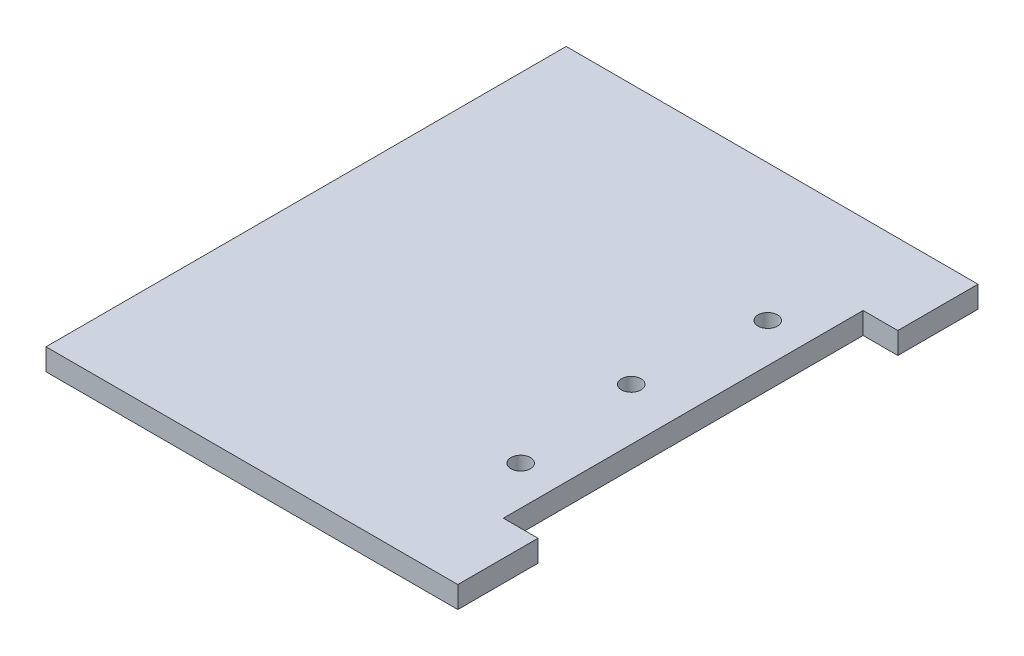
from build123d import *

# Parameters (mm, degrees)
SKETCH1_W                  = 95
SKETCH1_H                  = 120
BOSS_EXTRUDE1_DEPTH        = 5
SKETCH2_W                  = 83
SKETCH2_H                  = 5
CUT_EXTRUDE1_DEPTH         = 8
F_4_5_4_5_DIAMETER_HOLE1_D = 4.5


with BuildPart() as part:
    # Sketch1 → Boss-Extrude1 (new body)
    with BuildSketch(Plane(origin=(0, 0, 0), x_dir=(1, 0, 0), z_dir=(0, 1, 0))):
        Rectangle(SKETCH1_W, SKETCH1_H)
    extrude(amount=BOSS_EXTRUDE1_DEPTH)

    # Sketch2 → Cut-Extrude1 (cut)
    with BuildSketch(Plane(origin=(47.5, 0, 0), x_dir=(0, 0, -1), z_dir=(1, 0, 0))):
        with Locations((0, 2.5)):
            Rectangle(SKETCH2_W, SKETCH2_H)
    extrude(amount=-CUT_EXTRUDE1_DEPTH, mode=Mode.SUBTRACT)

    # Ø4.5 (4.5) Diameter Hole1 (through all)
    with Locations(Plane(origin=(0, 5, 0), x_dir=(1, 0, 0), z_dir=(0, 1, 0))):
        with Locations((30.5, 28.5), (27.5, 0), (30.5, -28.5)):
            Hole(F_4_5_4_5_DIAMETER_HOLE1_D / 2)


solid = part.part
